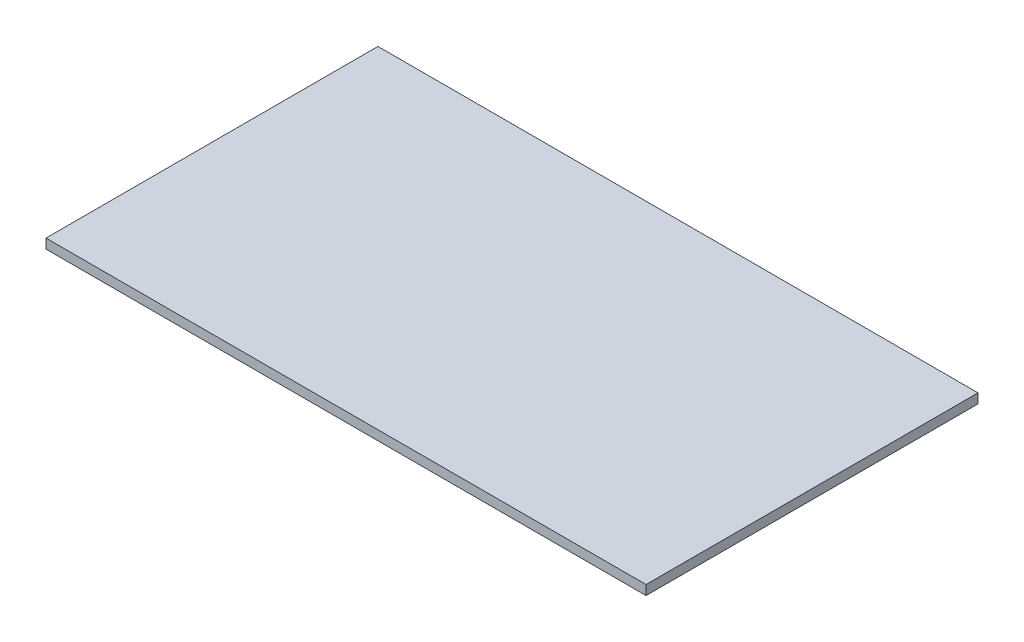
from build123d import *

# Parameters (mm, degrees)
SKETCH1_W           = 298.45
SKETCH1_H           = 165.1
BOSS_EXTRUDE1_DEPTH = 4.7625


with BuildPart() as part:
    # Sketch1 → Boss-Extrude1 (new body)
    with BuildSketch(Plane(origin=(0, 0, 0), x_dir=(1, 0, 0), z_dir=(0, 1, 0))):
        with Locations((149.225, -82.55)):
            Rectangle(SKETCH1_W, SKETCH1_H)
    extrude(amount=BOSS_EXTRUDE1_DEPTH)


solid = part.part
